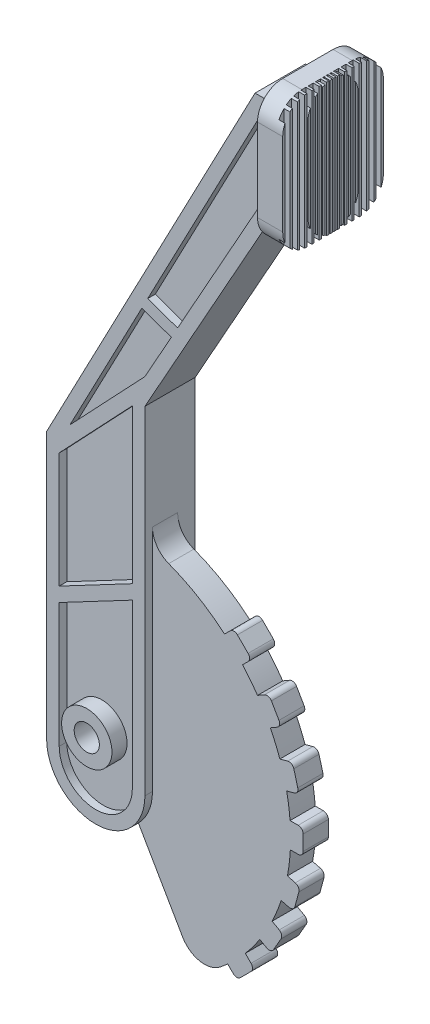
from build123d import *

# Parameters (mm, degrees)
BOSS_EXTRUDE1_DEPTH = 10
BOSS_EXTRUDE2_DEPTH = 10
SKETCH3_W           = 3.5
SKETCH3_H           = 2
CUT_EXTRUDE1_DEPTH  = 53.85
CUT_EXTRUDE2_DEPTH  = 3
SKETCH6_R           = 10
SKETCH6_R_2         = 5
BOSS_EXTRUDE3_DEPTH = 6
SKETCH7_R           = 5
BOSS_EXTRUDE4_DEPTH = 17
SKETCH8_R           = 5
CUT_EXTRUDE3_DEPTH  = 18
BOSS_EXTRUDE5_DEPTH = 10
FILLET1_R           = 10
SKETCH13_R          = 5
CUT_EXTRUDE4_DEPTH  = 34
BOSS_EXTRUDE6_DEPTH = 10
CIRPATTERN1_COUNT   = 4
CIRPATTERN1_ANGLE   = 45
CIRPATTERN2_COUNT   = 4
CIRPATTERN2_ANGLE   = 45


with BuildPart() as part:
    # Sketch1 → Boss-Extrude1 (new body)
    with BuildSketch(Plane.XY):
        with BuildLine():
            Line((0, 0), (0, 31.82))
            Line((0, 31.82), (-10.99, 31.82))
            Line((-10.99, 31.82), (-93.795, -126.01))
            Line((-93.795, -126.01), (-93.795, -231.86))
            ThreePointArc((-93.795, -231.86), (-74.27, -251.385), (-54.745, -231.86))
            Line((-54.745, -231.86), (-54.745, -97.84))
            Line((-54.745, -97.84), (0, 0))
        make_face()
    extrude(amount=BOSS_EXTRUDE1_DEPTH)

    # Sketch2 → Boss-Extrude2 (add)
    with BuildSketch(Plane(origin=(0, 0, 0), x_dir=(0, 0, -1), z_dir=(1, 0, 0))):
        with BuildLine():
            Line((-10, -10.515), (0, -10.515))
            ThreePointArc((0, -10.515), (7.071067812, -7.586067812), (10, -0.515))
            Line((10, -0.515), (10, 32.335))
            ThreePointArc((10, 32.335), (7.071067812, 39.406067812), (0, 42.335))
            Line((0, 42.335), (-10, 42.335))
            ThreePointArc((-10, 42.335), (-17.071067812, 39.406067812), (-20, 32.335))
            Line((-20, 32.335), (-20, -0.515))
            ThreePointArc((-20, -0.515), (-17.071067812, -7.586067812), (-10, -10.515))
        make_face()
    extrude(amount=BOSS_EXTRUDE2_DEPTH)

    # Sketch3 → Cut-Extrude1 (cut, through all)
    with BuildSketch(Plane.XZ.offset(10.515)):
        with Locations((9.38, -5.1)):
            Rectangle(SKETCH3_W, SKETCH3_H)
        with Locations((9.38, -8)):
            Rectangle(SKETCH3_W, SKETCH3_H)
        with Locations((9.38, -2.2)):
            Rectangle(SKETCH3_W, SKETCH3_H)
        with Locations((9.38, 0.7)):
            Rectangle(SKETCH3_W, SKETCH3_H)
        with Locations((9.38, 3.6)):
            Rectangle(SKETCH3_W, SKETCH3_H)
        with Locations((9.38, 6.5)):
            Rectangle(SKETCH3_W, SKETCH3_H)
        with Locations((9.38, 9.4)):
            Rectangle(SKETCH3_W, SKETCH3_H)
        with Locations((9.38, 12.3)):
            Rectangle(SKETCH3_W, SKETCH3_H)
        with Locations((9.38, 15.2)):
            Rectangle(SKETCH3_W, SKETCH3_H)
        with Locations((9.38, 18.1)):
            Rectangle(SKETCH3_W, SKETCH3_H)
    extrude(amount=-CUT_EXTRUDE1_DEPTH, mode=Mode.SUBTRACT)

    # Sketch4 → Cut-Extrude2 (cut)
    with BuildSketch(Plane.XY.offset(10)):
        Polygon((-59.745, -161.37046828), (-88.795, -176.7233287), (-88.795, -130.879670886), (-59.745, -100.173950044), align=None)
        with BuildLine():
            Line((-88.795, -182.378657825), (-88.795, -231.86))
            ThreePointArc((-88.795, -231.86), (-74.27, -246.385), (-59.745, -231.86))
            Line((-59.745, -231.86), (-59.745, -167.025797404))
            Line((-59.745, -167.025797404), (-88.795, -182.378657825))
        make_face()
        Polygon((-84.510576653, -119.075685736), (-54.763233039, -87.632875794), (-44.244384707, -68.833640781), (-55.955320015, -64.648100986), align=None)
        Polygon((-7.966876106, 26.82), (-53.609452758, -60.176774023), (-41.76851448, -64.408777451), (-5, 1.303734316), (-5, 26.82), align=None)
    extrude(amount=-CUT_EXTRUDE2_DEPTH, mode=Mode.SUBTRACT)

    # Sketch6 → Boss-Extrude3 (add)
    with BuildSketch(Plane.XY.offset(7)):
        with Locations((-74.850988184, -220.371467837)):
            Circle(SKETCH6_R)
        with Locations((-74.850988184, -220.371467837)):
            Circle(SKETCH6_R_2, mode=Mode.SUBTRACT)
    extrude(amount=BOSS_EXTRUDE3_DEPTH)

    # Sketch7 → Boss-Extrude4 (add, through all)
    with BuildSketch(Plane.XY.offset(7)):
        with Locations((-74.850988184, -220.371467837)):
            Circle(SKETCH7_R)
    extrude(amount=-BOSS_EXTRUDE4_DEPTH)

    # Sketch8 → Cut-Extrude3 (cut, through all)
    with BuildSketch(Plane.XY.offset(7)):
        with Locations((-74.850988184, -220.371467837)):
            Circle(SKETCH8_R)
    extrude(amount=-CUT_EXTRUDE3_DEPTH, mode=Mode.SUBTRACT)

    # Mirror2: part across plane


with BuildPart() as part_1:
    add(part.part)
    add(part.part.mirror(Plane(origin=(0, 0, 0), x_dir=(1, 0, 0), z_dir=(0, 0, -1))))

    # Sketch9 → Boss-Extrude5 (add)
    with BuildSketch(Plane.XY.offset(7)):
        with BuildLine():
            Line((-74.850988184, -145.371467837), (-74.850988184, -220.371467837))
            Line((-74.850988184, -220.371467837), (-37.350988184, -285.323373121))
            ThreePointArc((-37.350988184, -285.323373121), (-2.406551212, -200.960039454), (-74.850988184, -145.371467837))
        make_face()
    extrude(amount=-BOSS_EXTRUDE5_DEPTH)

    # Fillet1
    fillet1_edges = [part_1.edges().sort_by_distance(p)[0] for p in [
        (-54.745, -148.116715473, 2),
        (-37.350988184, -285.323373121, 2),
    ]]
    fillet(fillet1_edges, radius=FILLET1_R)

    # Sketch13 → Cut-Extrude4 (cut, through all)
    with BuildSketch(Plane.XY.offset(13)):
        with Locations((-74.850988184, -220.371467837)):
            Circle(SKETCH13_R)
    extrude(amount=-CUT_EXTRUDE4_DEPTH, mode=Mode.SUBTRACT)

    # Sketch14 → Boss-Extrude6 (add)
    with BuildSketch(Plane.XY.offset(7)):
        with BuildLine():
            Line((-4.855534124, -214.545713418), (3.144465876, -214.545713418))
            ThreePointArc((3.144465876, -214.545713418), (4.558679438, -215.131499856), (5.144465876, -216.545713418))
            Line((5.144465876, -216.545713418), (5.144465876, -222.545713418))
            ThreePointArc((5.144465876, -222.545713418), (4.558679438, -223.959926981), (3.144465876, -224.545713418))
            Line((3.144465876, -224.545713418), (-4.855534124, -224.545713418))
            Line((-4.855534124, -224.545713418), (-4.855534124, -214.545713418))
        make_face()
    boss_extrude6 = extrude(amount=-BOSS_EXTRUDE6_DEPTH)

    # CirPattern1: Boss-Extrude6 ×4 about axis
    cirpattern1_axis = Axis((-74.850988184, -220.371467837, 0), (0, 0, 1))
    for i in range(1, CIRPATTERN1_COUNT):
        add(boss_extrude6.rotate(cirpattern1_axis, i * CIRPATTERN1_ANGLE / (CIRPATTERN1_COUNT - 1)))

    # CirPattern2: Boss-Extrude6 ×4 about axis
    cirpattern2_axis = Axis((-74.850988184, -220.371467837, 0), (0, 0, -1))
    for i in range(1, CIRPATTERN2_COUNT):
        add(boss_extrude6.rotate(cirpattern2_axis, i * CIRPATTERN2_ANGLE / (CIRPATTERN2_COUNT - 1)))


solid = part_1.part
